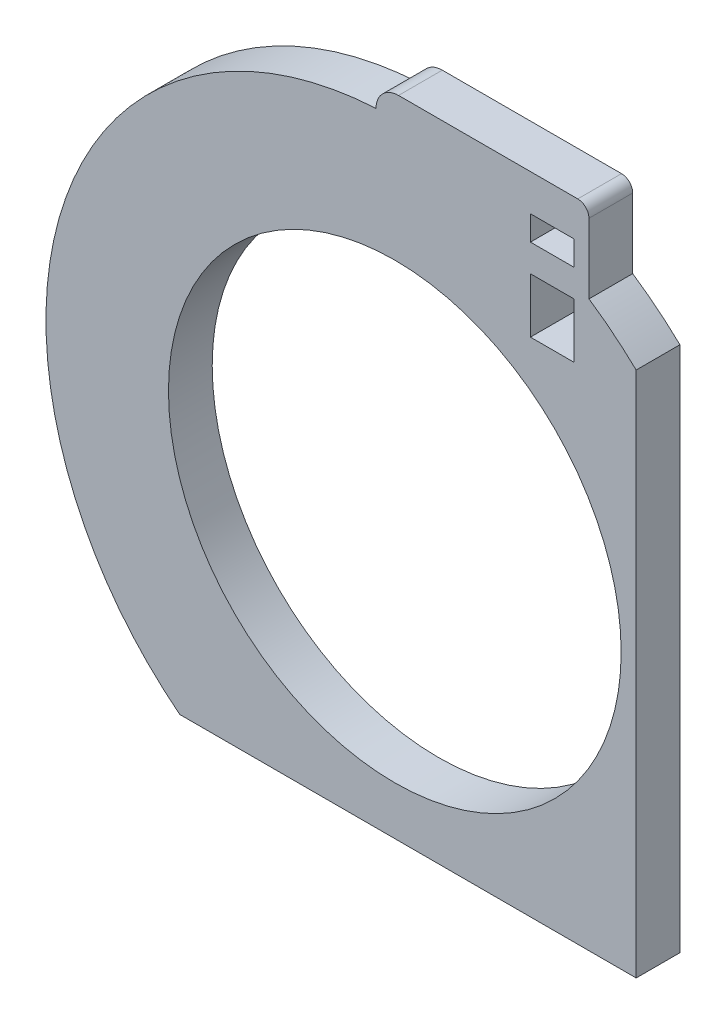
from build123d import *

# Parameters (mm, degrees)
SKETCH1_R           = 25.869040911
BOSS_EXTRUDE1_DEPTH = 5
CUT_EXTRUDE1_REACH  = 7
SKETCH2_W           = 5
SKETCH2_H           = 2.807032228
SKETCH2_H_2         = 6.272905991


with BuildPart() as part:
    # Sketch1 → Boss-Extrude1 (new body)
    with BuildSketch(Plane.XY):
        with BuildLine():
            Line((27.585503877, -31.392941885), (-24.576892053, -31.392941885))
            ThreePointArc((-24.576892053, -31.392941885), (-38.026656197, 11.979726275), (-2.145068244, 39.811293691))
            ThreePointArc((-2.145068244, 39.811293691), (-1.391692185, 41.630104391), (0.427118514, 42.38348045))
            Line((0.427118514, 42.38348045), (20.910674351, 42.38348045))
            ThreePointArc((20.910674351, 42.38348045), (21.815017729, 42.008889157), (22.189609022, 41.104545778))
            Line((22.189609022, 41.104545778), (22.189609022, 33.1234309))
            ThreePointArc((22.189609022, 33.1234309), (24.981909543, 31.071604702), (27.585503877, 28.785072503))
            Line((27.585503877, 28.785072503), (27.585503877, -31.392941885))
        make_face()
        Circle(SKETCH1_R, mode=Mode.SUBTRACT)
    extrude(amount=BOSS_EXTRUDE1_DEPTH)

    # Sketch2 → Cut-Extrude1 (cut, up to next)
    with BuildSketch(Plane(origin=(0, 0, 0), x_dir=(-1, 0, 0), z_dir=(0, 0, -1)), mode=Mode.PRIVATE) as cut_extrude1_sk1:
        with Locations((-18, 36.803720292)):
            Rectangle(SKETCH2_W, SKETCH2_H)
    cut_extrude1_tool1 = extrude(cut_extrude1_sk1.sketch, amount=-CUT_EXTRUDE1_REACH, mode=Mode.PRIVATE) & part.part
    add(cut_extrude1_tool1.solids().sort_by_distance((18, 36.80372, 0))[0], mode=Mode.SUBTRACT)
    # Sketch2 → Cut-Extrude1 (cut, up to next)
    with BuildSketch(Plane(origin=(0, 0, 0), x_dir=(-1, 0, 0), z_dir=(0, 0, -1)), mode=Mode.PRIVATE) as cut_extrude1_sk2:
        with Locations((-18, 29.132248973)):
            Rectangle(SKETCH2_W, SKETCH2_H_2)
    cut_extrude1_tool2 = extrude(cut_extrude1_sk2.sketch, amount=-CUT_EXTRUDE1_REACH, mode=Mode.PRIVATE) & part.part
    add(cut_extrude1_tool2.solids().sort_by_distance((18, 29.132249, 0))[0], mode=Mode.SUBTRACT)


solid = part.part
